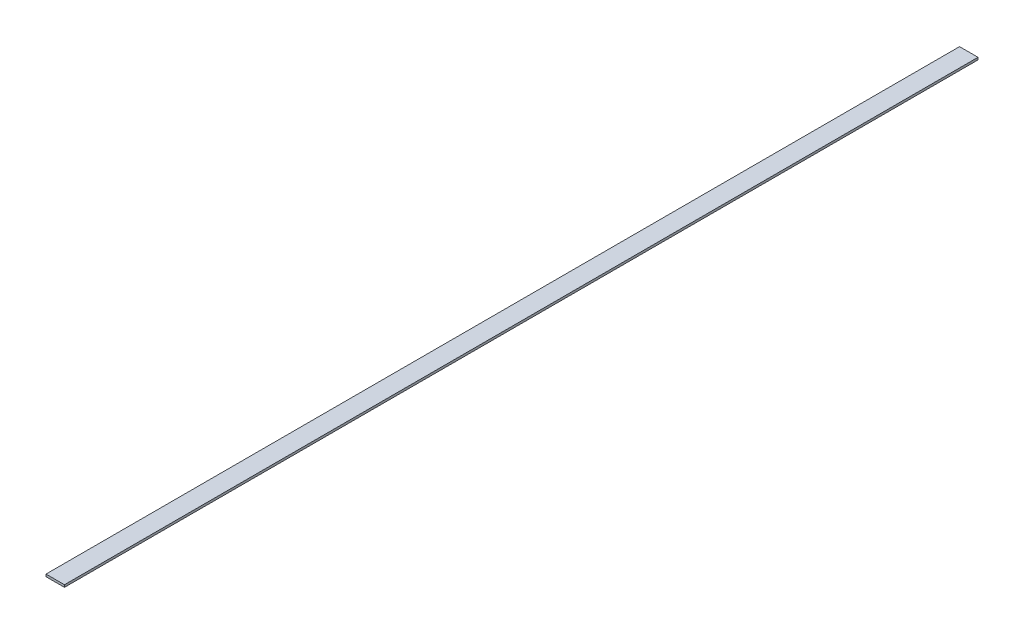
from build123d import *

# Parameters (mm, degrees)
ESQUISSE1_W        = 40
ESQUISSE1_H        = 5
BOSS_EXTRU_1_DEPTH = 1980


with BuildPart() as part:
    # Esquisse1 → Boss.-Extru.1 (new body)
    with BuildSketch(Plane.XY):
        with Locations((20, 2.5)):
            Rectangle(ESQUISSE1_W, ESQUISSE1_H)
    extrude(amount=BOSS_EXTRU_1_DEPTH)


solid = part.part
